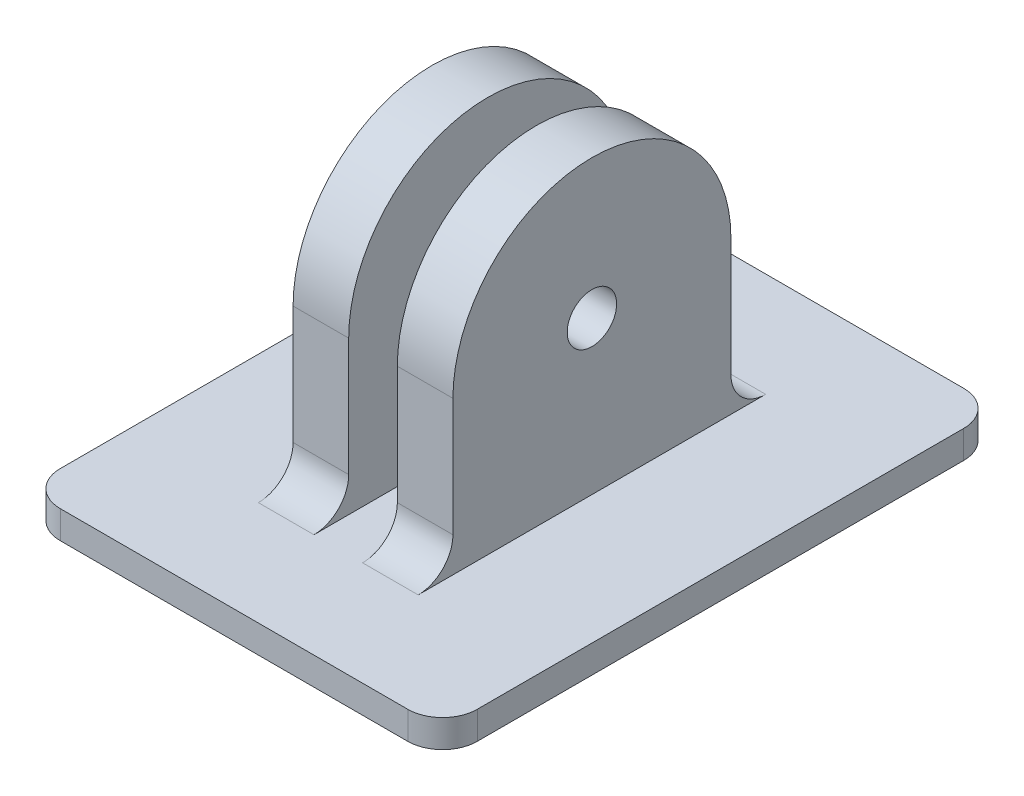
from build123d import *

# Parameters (mm, degrees)
ESQUISSE1_W             = 30
ESQUISSE1_H             = 40
BOSS_EXTRU_1_DEPTH      = 2
ESQUISSE2_W             = 4
ESQUISSE2_H             = 20
BOSS_EXTRU_2_DEPTH      = 11
BOSS_EXTRU_3_START      = -4
BOSS_EXTRU_3_DEPTH      = 4
BOSS_EXTRU_4_START      = -4
BOSS_EXTRU_4_DEPTH      = 4
ESQUISSE5_R             = 1.778
ENL_V_MAT_EXTRU_1_DEPTH = 11.5
CONG_1_R                = 2.5


with BuildPart() as part:
    # Esquisse1 → Boss.-Extru.1 (new body)
    with BuildSketch(Plane(origin=(0, 0, 0), x_dir=(1, 0, 0), z_dir=(0, 1, 0))):
        Rectangle(ESQUISSE1_W, ESQUISSE1_H)
    extrude(amount=BOSS_EXTRU_1_DEPTH)

    # Esquisse2 → Boss.-Extru.2 (add)
    with BuildSketch(Plane(origin=(0, 2, 0), x_dir=(1, 0, 0), z_dir=(0, 1, 0))):
        with Locations((3.75, 0)):
            Rectangle(ESQUISSE2_W, ESQUISSE2_H)
        with Locations((-3.75, 0)):
            Rectangle(ESQUISSE2_W, ESQUISSE2_H)
    extrude(amount=BOSS_EXTRU_2_DEPTH)

    # Esquisse3 → Boss.-Extru.3 (add)
    with BuildSketch(Plane.ZY.offset(5.75).offset(BOSS_EXTRU_3_START)):
        with BuildLine():
            Line((-10, 13), (10, 13))
            ThreePointArc((10, 13), (0, 23), (-10, 13))
        make_face()
    extrude(amount=BOSS_EXTRU_3_DEPTH)

    # Esquisse4 → Boss.-Extru.4 (add)
    with BuildSketch(Plane(origin=(5.75, 0, 0), x_dir=(0, 0, -1), z_dir=(1, 0, 0)).offset(BOSS_EXTRU_4_START)):
        with BuildLine():
            Line((10, 13), (-10, 13))
            ThreePointArc((-10, 13), (0, 23), (10, 13))
        make_face()
    extrude(amount=BOSS_EXTRU_4_DEPTH)

    # Esquisse5 → Enlèv. mat.-Extru.1 (cut)
    with BuildSketch(Plane(origin=(5.75, 0, 0), x_dir=(0, 0, -1), z_dir=(1, 0, 0))):
        with Locations((0, 13)):
            Circle(ESQUISSE5_R)
    extrude(amount=-ENL_V_MAT_EXTRU_1_DEPTH, mode=Mode.SUBTRACT)

    # Congé1
    cong_1_edges = [part.edges().sort_by_distance(p)[0] for p in [
        (3.75, 2, 10),
        (3.75, 2, -10),
        (-3.75, 2, -10),
        (-3.75, 2, 10),
        (-15, 1, -20),
        (15, 1, -20),
        (15, 1, 20),
        (-15, 1, 20),
    ]]
    fillet(cong_1_edges, radius=CONG_1_R)


solid = part.part
